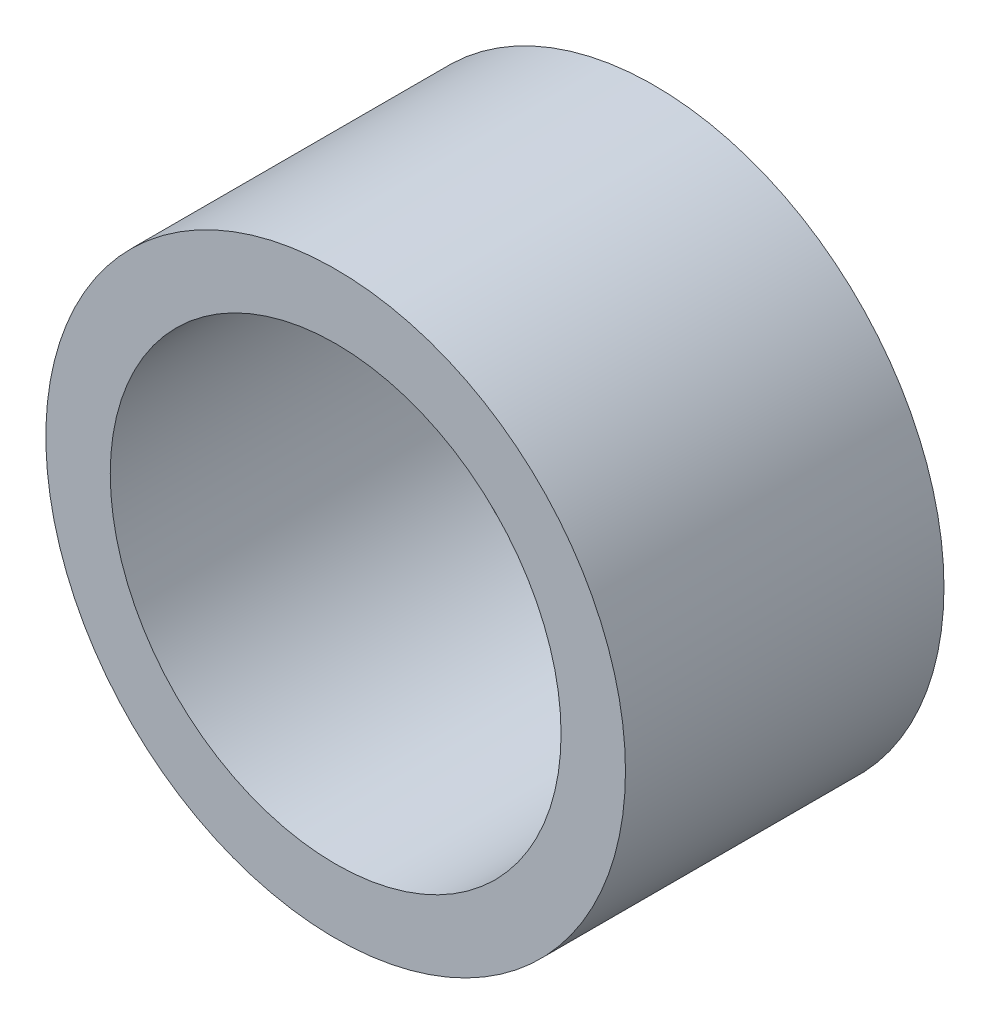
from build123d import *

# Parameters (mm, degrees)
SKETCH1_R           = 14.2875
SKETCH1_R_2         = 11.1125
BOSS_EXTRUDE1_DEPTH = 15.70228


with BuildPart() as part:
    # Sketch1 → Boss-Extrude1 (new body)
    with BuildSketch(Plane.XY):
        Circle(SKETCH1_R)
        Circle(SKETCH1_R_2, mode=Mode.SUBTRACT)
    extrude(amount=BOSS_EXTRUDE1_DEPTH)


solid = part.part
